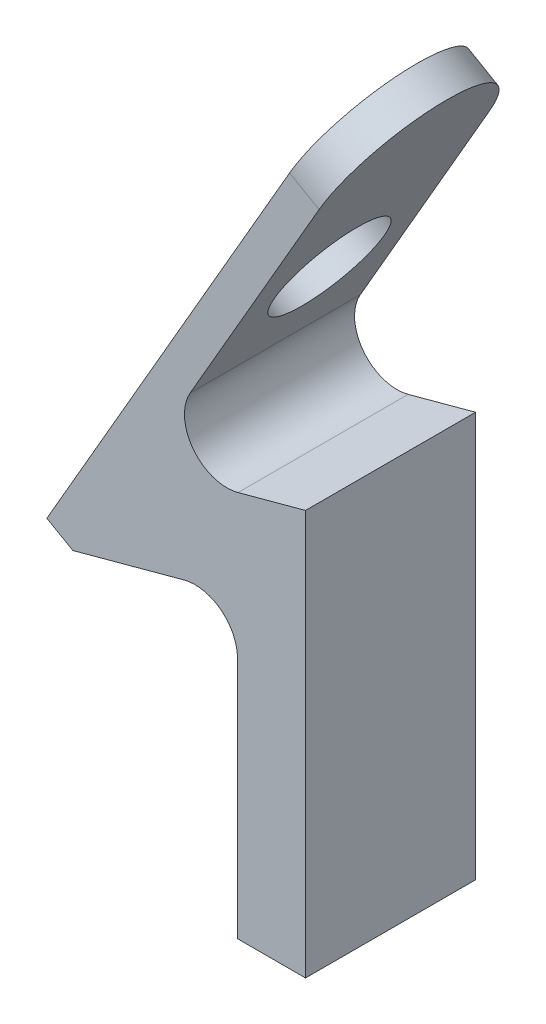
from build123d import *

# Parameters (mm, degrees)
BOSS_EXTRU_1_DEPTH      = 20
CONG_1_R                = 5
CHANFREIN1_SIZE2        = 5
CHANFREIN1_SIZE         = 3.535545122
BOSS_EXTRU_2_DEPTH      = 4
ESQUISSE9_W             = 20
ESQUISSE9_H             = 48.160254038
ENL_V_MAT_EXTRU_5_DEPTH = 2
ESQUISSE10_R            = 6.5
ENL_V_MAT_EXTRU_6_DEPTH = 4


with BuildPart() as part:
    # Esquisse1 → Boss.-Extru.1 (new body)
    with BuildSketch(Plane.XY.offset(164.870489571)):
        Polygon((-68.588600326, 5.142765071), (-68.588600326, 15.502551901), (-78.588600326, 12.796044343), (-90.211700696, 9.650243444), (-68.996801706, 46.395526372), (-72.460903321, 48.395526372), (-102.774849854, -4.109769201), (-78.588600326, 2.436257514), (-78.588600326, -32.657702137), (-68.588600326, -32.657702137), align=None)
    extrude(amount=-BOSS_EXTRU_1_DEPTH)

    # Congé1
    cong_1_edges = [part.edges().sort_by_distance(p)[0] for p in [
        (-90.211700696, 9.650243444, 154.870489571),
        (-78.588600326, 2.436257514, 154.870489571),
    ]]
    fillet(cong_1_edges, radius=CONG_1_R)

    # Chanfrein1
    chanfrein1_edges = [part.edges().sort_by_distance(p)[0] for p in [
        (-102.774849854, -4.109769201, 154.870489571),
    ]]
    chamfer(chanfrein1_edges, length=CHANFREIN1_SIZE, length2=CHANFREIN1_SIZE2)

    # Esquisse8 → Boss.-Extru.2 (add)
    with BuildSketch(Plane(origin=(-75.301555125, 43.475373122, 0), x_dir=(0, 0, 1), z_dir=(-0.866025404, 0.5, 0))):
        with BuildLine():
            Line((144.870489571, 5.681303607), (164.870489571, 5.681303607))
            ThreePointArc((164.870489571, 5.681303607), (154.870489571, 15.681303607), (144.870489571, 5.681303607))
        make_face()
    extrude(amount=-BOSS_EXTRU_2_DEPTH)

    # Esquisse9 → Enlèv. mat.-Extru.5 (cut)
    with BuildSketch(Plane(origin=(-68.588600326, 0, 0), x_dir=(0, 0, -1), z_dir=(1, 0, 0))):
        with Locations((-154.870489571, -8.577575118)):
            Rectangle(ESQUISSE9_W, ESQUISSE9_H)
    extrude(amount=-ENL_V_MAT_EXTRU_5_DEPTH, mode=Mode.SUBTRACT)

    # Esquisse10 → Enlèv. mat.-Extru.6 (cut)
    with BuildSketch(Plane(origin=(-75.301555125, 43.475373122, 0), x_dir=(0, 0, 1), z_dir=(-0.866025404, 0.5, 0))):
        with Locations((154.870489571, -11.868696393)):
            Circle(ESQUISSE10_R)
    extrude(amount=-ENL_V_MAT_EXTRU_6_DEPTH, mode=Mode.SUBTRACT)


solid = part.part
